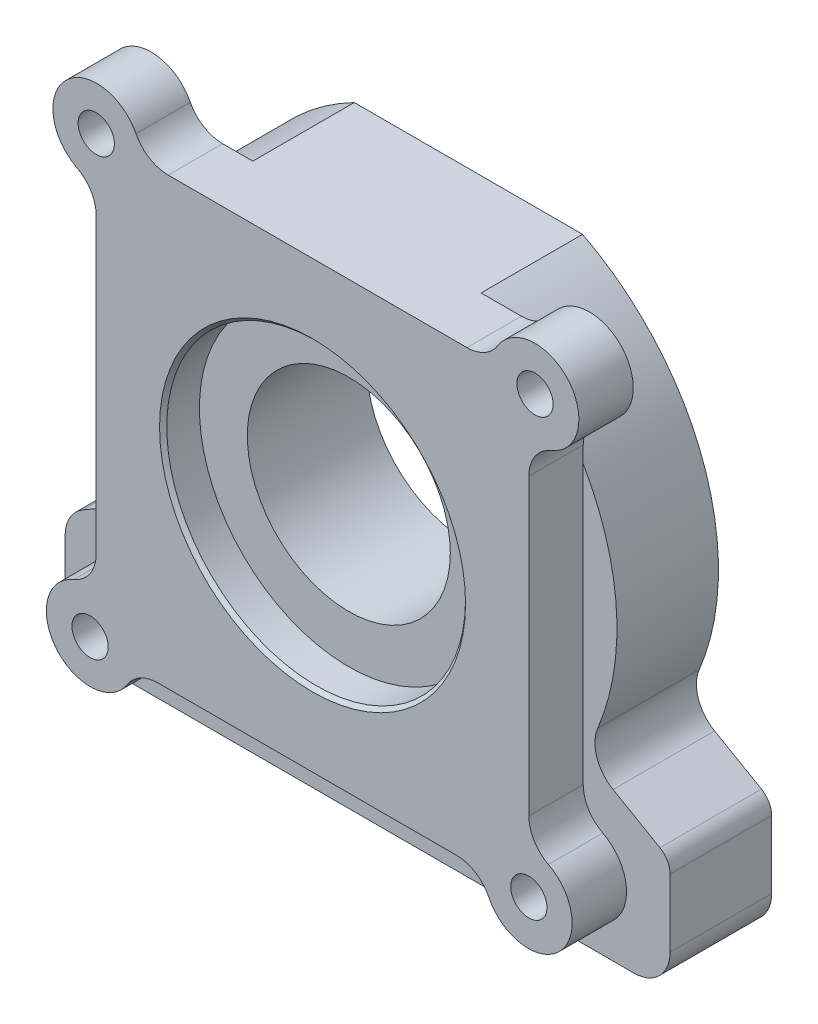
from build123d import *

# Parameters (mm, degrees)
SKETCH1_R               = 6.35
EXTRUDE1_DEPTH          = 19.05
FILLET1_R               = 12.7
SKETCH2_R               = 52.327921125
CUT_EXTRUDE2_DEPTH      = 12.7
CHAMFER1_SIZE           = 1.27
EXTRUDE2_DEPTH          = 35.56
SKETCH3_R               = 35.56
CUT_EXTRUDE3_DEPTH      = 20.05
CUT_EXTRUDE3_DEPTH_BACK = 36.56
SKETCH5_W               = 101.416551859
SKETCH5_H               = 41.189513353
CUT_EXTRUDE4_DEPTH      = 40.64
SKETCH7_R               = 6.35
CUT_EXTRUDE6_DEPTH      = 36.56


with BuildPart() as part:
    # Sketch1 → Extrude1 (new body)
    with BuildSketch(Plane.XY):
        with BuildLine():
            Line((-60.195770425, 77.931349549), (62.709585641, 77.931349549))
            ThreePointArc((62.709585641, 77.931349549), (90.219330448, 85.014128276), (75.775284214, 60.553520307))
            Line((75.775284214, 60.553520307), (75.775284214, -62.895919466))
            ThreePointArc((75.775284214, -62.895919466), (86.24662402, -89.329307316), (60.199368708, -77.931349549))
            Line((60.199368708, -77.931349549), (-62.691575683, -77.931349549))
            ThreePointArc((-62.691575683, -77.931349549), (-90.218375384, -84.744460999), (-75.775284214, -60.340766466))
            Line((-75.775284214, -60.340766466), (-75.775284214, 62.510464201))
            ThreePointArc((-75.775284214, 62.510464201), (-86.384477207, 88.809119355), (-60.195770425, 77.931349549))
        make_face()
        with Locations((77.931349549, 75.775284214)):
            Circle(SKETCH1_R, mode=Mode.SUBTRACT)
        with Locations((75.775284214, -77.931349549)):
            Circle(SKETCH1_R, mode=Mode.SUBTRACT)
        with Locations((-77.931349549, -75.775284214)):
            Circle(SKETCH1_R, mode=Mode.SUBTRACT)
        with Locations((-75.775284214, 77.931349549)):
            Circle(SKETCH1_R, mode=Mode.SUBTRACT)
    extrude(amount=EXTRUDE1_DEPTH)

    # Fillet1
    fillet1_edges = [part.edges().sort_by_distance(p)[0] for p in [
        (-75.775284214, -60.340766466, 9.525),
        (-75.775284214, 62.510464201, 9.525),
        (-60.195770425, 77.931349549, 9.525),
        (62.709585641, 77.931349549, 9.525),
        (75.775284214, 60.553520307, 9.525),
        (75.775284214, -62.895919466, 9.525),
        (60.199368708, -77.931349549, 9.525),
        (-62.691575683, -77.931349549, 9.525),
    ]]
    fillet(fillet1_edges, radius=FILLET1_R)

    # Sketch2 → Cut-Extrude2 (cut)
    with BuildSketch(Plane.XY.offset(19.05)):
        Circle(SKETCH2_R)
    extrude(amount=-CUT_EXTRUDE2_DEPTH, mode=Mode.SUBTRACT)

    # Chamfer1
    chamfer1_edges = [part.edges().sort_by_distance(p)[0] for p in [
        (-52.327921125, 0, 19.05),
    ]]
    chamfer(chamfer1_edges, length=CHAMFER1_SIZE)

    # Sketch4 → Extrude2 (add)
    with BuildSketch(Plane(origin=(0, 0, 0), x_dir=(-1, 0, 0), z_dir=(0, 0, -1))):
        with BuildLine():
            Line((86.089983669, -49.856504988), (99.397574405, -57.563208318))
            ThreePointArc((99.397574405, -57.563208318), (104.035719005, -62.2105938), (105.732985822, -68.553295314))
            Line((105.732985822, -68.553295314), (105.732985822, -88.945536156))
            ThreePointArc((105.732985822, -88.945536156), (102.013241943, -97.925792277), (93.032985822, -101.645536156))
            Line((93.032985822, -101.645536156), (-93.521645158, -101.645536156))
            ThreePointArc((-93.521645158, -101.645536156), (-102.501901279, -97.925792277), (-106.221645158, -88.945536156))
            Line((-106.221645158, -88.945536156), (-106.221645158, -65.233714494))
            ThreePointArc((-106.221645158, -65.233714494), (-105.262508623, -61.659777941), (-102.642852051, -59.046281274))
            Line((-102.642852051, -59.046281274), (-86.23402563, -49.606947108))
            ThreePointArc((-86.23402563, -49.606947108), (-80.539133122, -42.676006174), (-80.844982944, -33.710728777))
            ThreePointArc((-80.844982944, -33.710728777), (0.126849431, 87.591714284), (80.747004975, -33.944744652))
            ThreePointArc((80.747004975, -33.944744652), (80.415189643, -42.909098588), (86.089983669, -49.856504988))
        make_face()
    extrude(amount=EXTRUDE2_DEPTH)

    # Sketch3 → Cut-Extrude3 (cut, two sides)
    with BuildSketch(Plane.XY) as cut_extrude3_sk:
        Circle(SKETCH3_R)
    extrude(amount=CUT_EXTRUDE3_DEPTH, mode=Mode.SUBTRACT)
    extrude(cut_extrude3_sk.sketch, amount=-CUT_EXTRUDE3_DEPTH_BACK, mode=Mode.SUBTRACT)

    # Sketch5 → Cut-Extrude4 (cut)
    with BuildSketch(Plane.XY):
        with Locations((-2.36196921, 98.526106226)):
            Rectangle(SKETCH5_W, SKETCH5_H)
    extrude(amount=-CUT_EXTRUDE4_DEPTH, mode=Mode.SUBTRACT)

    # Sketch7 → Cut-Extrude6 (cut, through all)
    with BuildSketch(Plane.XY):
        with Locations((75.775284214, -77.931349549)):
            Circle(SKETCH7_R)
        with Locations((-77.931349549, -75.775284214)):
            Circle(SKETCH7_R)
    extrude(amount=-CUT_EXTRUDE6_DEPTH, mode=Mode.SUBTRACT)


solid = part.part
